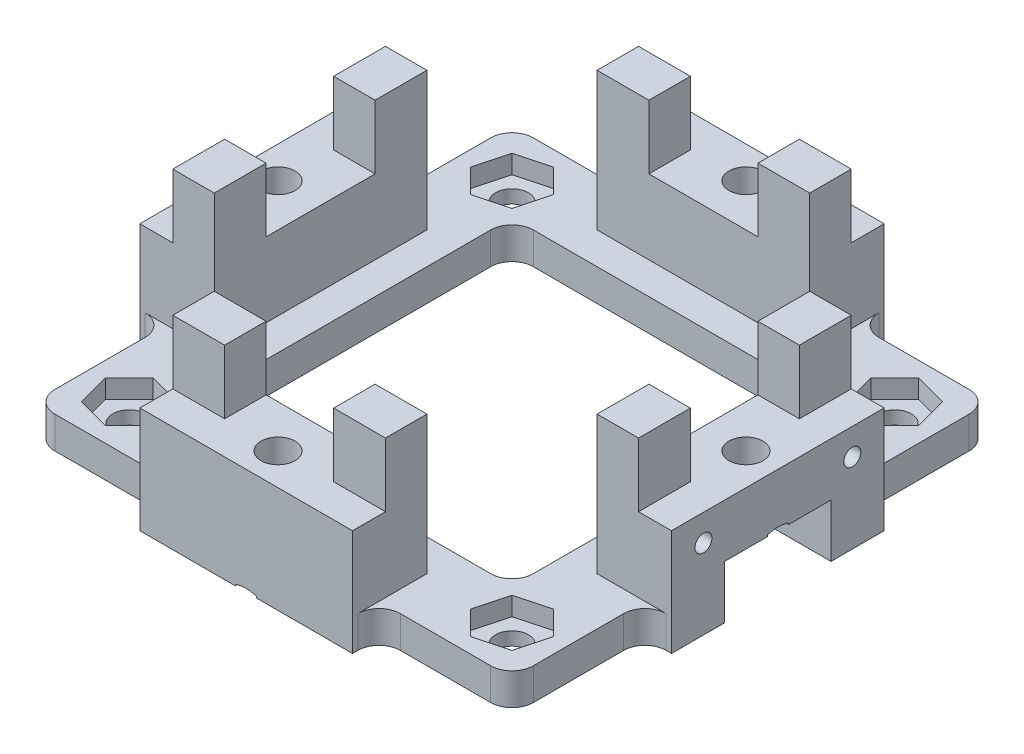
from build123d import *

# Parameters (mm, degrees)
SKETCH1_W                                      = 30
SKETCH1_H                                      = 30
BOSS_EXTRUDE1_DEPTH                            = 3
SKETCH2_W                                      = 20
SKETCH2_H                                      = 7
SKETCH2_W_2                                    = 7
SKETCH2_H_2                                    = 20
BOSS_EXTRUDE2_DEPTH                            = 7
SKETCH3_W                                      = 4.875
SKETCH3_H                                      = 3.9
SKETCH3_W_2                                    = 3.9
SKETCH3_H_2                                    = 4.875
BOSS_EXTRUDE3_DEPTH                            = 6
CSK_FOR_M3_FLAT_HEAD_MACHINE_SCREW1_AT_2_COUNT = 2
CSK_FOR_M3_FLAT_HEAD_MACHINE_SCREW1_AT_2_PITCH = 31.112698372
CSK_FOR_M3_FLAT_HEAD_MACHINE_SCREW1_AT_3_COUNT = 2
CSK_FOR_M3_FLAT_HEAD_MACHINE_SCREW1_AT_3_PITCH = 44
CSK_FOR_M3_FLAT_HEAD_MACHINE_SCREW1_AT_4_COUNT = 2
CSK_FOR_M3_FLAT_HEAD_MACHINE_SCREW1_AT_4_PITCH = 31.112698372
CSK_FOR_M3_FLAT_HEAD_MACHINE_SCREW1_AT_5_COUNT = 2
CSK_FOR_M3_FLAT_HEAD_MACHINE_SCREW1_AT_5_PITCH = 22
CUT_EXTRUDE1_DEPTH                             = 1.75
SKETCH7_R                                      = 1.55
CUT_EXTRUDE2_DEPTH                             = 4
FILLET1_R                                      = 2
SKETCH8_W                                      = 10
SKETCH8_H                                      = 10
CUT_EXTRUDE3_DEPTH                             = 5
SKETCH11_R                                     = 0.8
CUT_EXTRUDE4_DEPTH                             = 7


with BuildPart() as part:
    # Sketch1 → Boss-Extrude1 (new body)
    with BuildSketch(Plane(origin=(0, 0, 0), x_dir=(1, 0, 0), z_dir=(0, 1, 0))):
        Polygon((-10, 22.5), (-10, 25), (10, 25), (10, 22.5), (22.5, 22.5), (22.5, 10), (25, 10), (25, -10), (22.5, -10), (22.5, -22.5), (10, -22.5), (10, -25), (-10, -25), (-10, -22.5), (-22.5, -22.5), (-22.5, -10), (-25, -10), (-25, 10), (-22.5, 10), (-22.5, 22.5), align=None)
        Rectangle(SKETCH1_W, SKETCH1_H, mode=Mode.SUBTRACT)
    extrude(amount=BOSS_EXTRUDE1_DEPTH)

    # Sketch2 → Boss-Extrude2 (add)
    with BuildSketch(Plane(origin=(0, 3, 0), x_dir=(1, 0, 0), z_dir=(0, 1, 0))):
        with Locations((0, 21.5)):
            Rectangle(SKETCH2_W, SKETCH2_H)
        with Locations((21.5, 0)):
            Rectangle(SKETCH2_W_2, SKETCH2_H_2)
        with Locations((0, -21.5)):
            Rectangle(SKETCH2_W, SKETCH2_H)
        with Locations((-21.5, 0)):
            Rectangle(SKETCH2_W_2, SKETCH2_H_2)
    extrude(amount=BOSS_EXTRUDE2_DEPTH)

    # Sketch3 → Boss-Extrude3 (add)
    with BuildSketch(Plane(origin=(0, 10, 0), x_dir=(1, 0, 0), z_dir=(0, 1, 0))):
        with Locations((-7.5625, 19.95)):
            Rectangle(SKETCH3_W, SKETCH3_H)
        with Locations((7.5625, 19.95)):
            Rectangle(SKETCH3_W, SKETCH3_H)
        with Locations((19.95, 7.5625)):
            Rectangle(SKETCH3_W_2, SKETCH3_H_2)
        with Locations((19.95, -7.5625)):
            Rectangle(SKETCH3_W_2, SKETCH3_H_2)
        with Locations((7.5625, -19.95)):
            Rectangle(SKETCH3_W, SKETCH3_H)
        with Locations((-7.5625, -19.95)):
            Rectangle(SKETCH3_W, SKETCH3_H)
        with Locations((-19.95, -7.5625)):
            Rectangle(SKETCH3_W_2, SKETCH3_H_2)
        with Locations((-19.95, 7.5625)):
            Rectangle(SKETCH3_W_2, SKETCH3_H_2)
    extrude(amount=BOSS_EXTRUDE3_DEPTH)

    # Sketch4 → CSK for M3 Flat Head Machine Screw1 (revolve, cut)
    with BuildSketch(Plane(origin=(-22, 0, 0), x_dir=(0, 0, -1), z_dir=(1, 0, 0))):
        Polygon((0, 0), (0, 20.96137699), (1.6, 20), (1.6, 1.7), (3.15, 0.15), (3.15, 0), align=None)
    csk_for_m3_flat_head_machine_screw1 = revolve(axis=Axis((-22, -6.35, 0), (0, 1, 0)), mode=Mode.SUBTRACT)

    # CSK for M3 Flat Head Machine Screw1 at 2: CSK for M3 Flat Head Machine Screw1 ×2
    with Locations(*[Vector(0.707106781, 0, 0.707106781) * (i * CSK_FOR_M3_FLAT_HEAD_MACHINE_SCREW1_AT_2_PITCH) for i in range(1, CSK_FOR_M3_FLAT_HEAD_MACHINE_SCREW1_AT_2_COUNT)]):
        add(csk_for_m3_flat_head_machine_screw1, mode=Mode.SUBTRACT)

    # CSK for M3 Flat Head Machine Screw1 at 3: CSK for M3 Flat Head Machine Screw1 ×2
    with Locations(*[(i * CSK_FOR_M3_FLAT_HEAD_MACHINE_SCREW1_AT_3_PITCH, 0, 0) for i in range(1, CSK_FOR_M3_FLAT_HEAD_MACHINE_SCREW1_AT_3_COUNT)]):
        add(csk_for_m3_flat_head_machine_screw1, mode=Mode.SUBTRACT)

    # CSK for M3 Flat Head Machine Screw1 at 4: CSK for M3 Flat Head Machine Screw1 ×2
    with Locations(*[Vector(0.707106781, 0, -0.707106781) * (i * CSK_FOR_M3_FLAT_HEAD_MACHINE_SCREW1_AT_4_PITCH) for i in range(1, CSK_FOR_M3_FLAT_HEAD_MACHINE_SCREW1_AT_4_COUNT)]):
        add(csk_for_m3_flat_head_machine_screw1, mode=Mode.SUBTRACT)

    # CSK for M3 Flat Head Machine Screw1 at 5: CSK for M3 Flat Head Machine Screw1 ×2
    with Locations(*[(i * CSK_FOR_M3_FLAT_HEAD_MACHINE_SCREW1_AT_5_PITCH, 0, 0) for i in range(1, CSK_FOR_M3_FLAT_HEAD_MACHINE_SCREW1_AT_5_COUNT)]):
        add(csk_for_m3_flat_head_machine_screw1, mode=Mode.SUBTRACT)

    # Sketch6 → Cut-Extrude1 (cut)
    with BuildSketch(Plane(origin=(0, 3, 0), x_dir=(1, 0, 0), z_dir=(0, 1, 0))):
        Polygon((-20.245365598, 20.245365598), (-21.067226447, 17.178139151), (-18.821860849, 14.932773553), (-15.754634402, 15.754634402), (-14.932773553, 18.821860849), (-17.178139151, 21.067226447), align=None)
        Polygon((20.245365598, 20.245365598), (17.178139151, 21.067226447), (14.932773553, 18.821860849), (15.754634402, 15.754634402), (18.821860849, 14.932773553), (21.067226447, 17.178139151), align=None)
        Polygon((20.245365598, -20.245365598), (21.067226447, -17.178139151), (18.821860849, -14.932773553), (15.754634402, -15.754634402), (14.932773553, -18.821860849), (17.178139151, -21.067226447), align=None)
        Polygon((-20.245365598, -20.245365598), (-17.178139151, -21.067226447), (-14.932773553, -18.821860849), (-15.754634402, -15.754634402), (-18.821860849, -14.932773553), (-21.067226447, -17.178139151), align=None)
    extrude(amount=-CUT_EXTRUDE1_DEPTH, mode=Mode.SUBTRACT)

    # Sketch7 → Cut-Extrude2 (cut, through all)
    with BuildSketch(Plane(origin=(0, 3, 0), x_dir=(1, 0, 0), z_dir=(0, 1, 0))):
        with Locations((-18, 18)):
            Circle(SKETCH7_R)
        with Locations((18, 18)):
            Circle(SKETCH7_R)
        with Locations((18, -18)):
            Circle(SKETCH7_R)
        with Locations((-18, -18)):
            Circle(SKETCH7_R)
    extrude(amount=-CUT_EXTRUDE2_DEPTH, mode=Mode.SUBTRACT)

    # Fillet1
    fillet1_edges = [part.edges().sort_by_distance(p)[0] for p in [
        (-15, 1.5, -15),
        (-15, 1.5, 15),
        (15, 1.5, 15),
        (15, 1.5, -15),
        (-10, 1.5, -22.5),
        (-22.5, 1.5, -10),
        (10, 1.5, -22.5),
        (22.5, 1.5, -10),
        (22.5, 1.5, 10),
        (10, 1.5, 22.5),
        (-10, 1.5, 22.5),
        (-22.5, 1.5, 10),
        (-22.5, 1.5, 22.5),
        (22.5, 1.5, 22.5),
        (22.5, 1.5, -22.5),
        (-22.5, 1.5, -22.5),
    ]]
    fillet(fillet1_edges, radius=FILLET1_R)

    # Sketch8 → Cut-Extrude3 (cut)
    with BuildSketch(Plane.XZ):
        with Locations((20, 0)):
            Rectangle(SKETCH8_W, SKETCH8_H)
    extrude(amount=-CUT_EXTRUDE3_DEPTH, mode=Mode.SUBTRACT)

    # Sketch9 → CSK for M3 Flat Head Machine Screw2 (revolve, cut)
    with BuildSketch(Plane(origin=(22, 5, 0), x_dir=(0, 0, -1), z_dir=(1, 0, 0))):
        Polygon((0, 0), (0, 20.96137699), (1.6, 20), (1.6, 1.7), (3.15, 0.15), (3.15, 0), align=None)
    revolve(axis=Axis((22, -1.35, 0), (0, 1, 0)), mode=Mode.SUBTRACT)

    # Sketch11 → Cut-Extrude4 (cut)
    with BuildSketch(Plane(origin=(25, 0, 0), x_dir=(0, 0, -1), z_dir=(1, 0, 0))):
        with Locations((7, 7.5)):
            Circle(SKETCH11_R)
        with Locations((-7, 7.5)):
            Circle(SKETCH11_R)
    extrude(amount=-CUT_EXTRUDE4_DEPTH, mode=Mode.SUBTRACT)


solid = part.part
